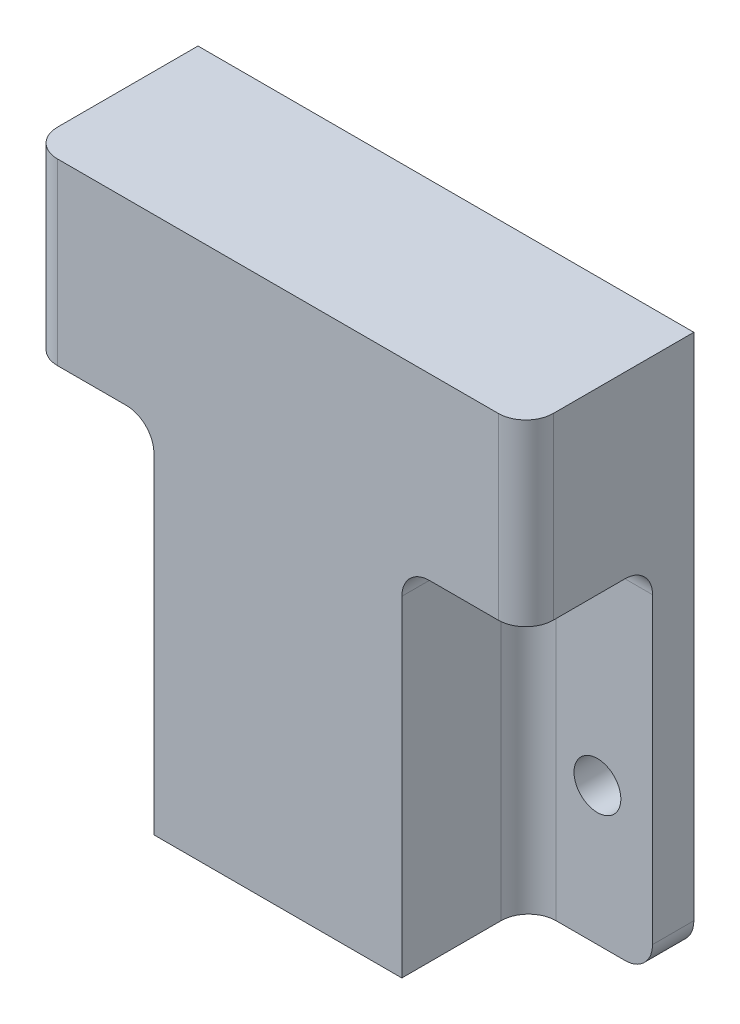
from build123d import *

# Parameters (mm, degrees)
SKIZZE1_W                       = 18
SKIZZE1_H                       = 10
AUFSATZ_LINEAR_AUSTRAGEN1_DEPTH = 3
DURCHGANGSLOCH_F_R_M31_D        = 3.4
SKIZZE5_W                       = 8
SKIZZE5_H                       = 3
AUFSATZ_LINEAR_AUSTRAGEN2_DEPTH = 3
AUFSATZ_LINEAR_AUSTRAGEN3_DEPTH = 10
AUFSATZ_LINEAR_AUSTRAGEN7_DEPTH = 9
SKIZZE19_W                      = 18
SKIZZE19_H                      = 3
AUFSATZ_LINEAR_AUSTRAGEN8_DEPTH = 9.2
VERRUNDUNG1_R                   = 2
VERRUNDUNG3_R                   = 2
AUFSATZ_LINEAR_AUSTRAGEN9_DEPTH = 10


with BuildPart() as part:
    # Skizze1 → Aufsatz-Linear austragen1 (new body)
    with BuildSketch(Plane.XY):
        with Locations((-9, 5)):
            Rectangle(SKIZZE1_W, SKIZZE1_H)
    extrude(amount=AUFSATZ_LINEAR_AUSTRAGEN1_DEPTH)

    # Durchgangsloch für M31 (through all)
    with Locations(Plane.XY.offset(3)):
        with Locations((-14, 0)):
            Hole(DURCHGANGSLOCH_F_R_M31_D / 2)

    # Skizze5 → Aufsatz-Linear austragen2 (add)
    with BuildSketch(Plane(origin=(0, 0, 0), x_dir=(-1, 0, 0), z_dir=(0, 0, -1))):
        with Locations((4, 1.5)):
            Rectangle(SKIZZE5_W, SKIZZE5_H)
    extrude(amount=AUFSATZ_LINEAR_AUSTRAGEN2_DEPTH)

    # Skizze7 → Aufsatz-Linear austragen3 (add)
    with BuildSketch(Plane(origin=(0, 10, 0), x_dir=(1, 0, 0), z_dir=(0, 1, 0))):
        Polygon((-6.5, -3), (-6.5, -9), (0, -9), (0, -12.2), (-9, -12.2), (-9, -3), align=None)
    extrude(amount=-AUFSATZ_LINEAR_AUSTRAGEN3_DEPTH)

    # Spiegeln2: part across plane


with BuildPart() as part_1:
    add(part.part)
    add(part.part.mirror(Plane(origin=(0, 0, 3), x_dir=(0, 0, 1), z_dir=(0, 1, 0))))

    # Skizze16 → Aufsatz-Linear austragen7 (add)
    with BuildSketch(Plane(origin=(0, 10, 0), x_dir=(1, 0, 0), z_dir=(0, 1, 0))):
        Polygon((0, 0), (-18, 0), (-18, -3), (-9, -3), (-9, -12.2), (0, -12.2), (0, -9), (-6.5, -9), (-6.5, -3), (0, -3), align=None)
    extrude(amount=AUFSATZ_LINEAR_AUSTRAGEN7_DEPTH)

    # Skizze19 → Aufsatz-Linear austragen8 (add)
    with BuildSketch(Plane.XY.offset(3)):
        with Locations((-9, 17.5)):
            Rectangle(SKIZZE19_W, SKIZZE19_H)
    extrude(amount=AUFSATZ_LINEAR_AUSTRAGEN8_DEPTH)

    # Verrundung1
    verrundung1_edges = [part_1.edges().sort_by_distance(p)[0] for p in [
        (-9, 16, 7.6),
        (-13.5, 16, 3),
        (-18, 17.5, 12.2),
        (-9, 5, 3),
    ]]
    fillet(verrundung1_edges, radius=VERRUNDUNG1_R)

    # Verrundung3
    verrundung3_edges = [part_1.edges().sort_by_distance(p)[0] for p in [
        (-18, -10, 1.5),
    ]]
    fillet(verrundung3_edges, radius=VERRUNDUNG3_R)

    # Spiegeln1: part across plane


with BuildPart() as part_2:
    add(part_1.part)
    add(part_1.part.mirror(Plane(origin=(0, 0, 3), x_dir=(0, 0, 1), z_dir=(-1, 0, 0))))

    # Skizze20 → Aufsatz-Linear austragen9 (add)
    with BuildSketch(Plane(origin=(0, 19, 0), x_dir=(1, 0, 0), z_dir=(0, 1, 0))):
        with BuildLine():
            Line((-18, 0), (-18, -10.2))
            ThreePointArc((-18, -10.2), (-17.414213562, -11.614213562), (-16, -12.2))
            Line((-16, -12.2), (16, -12.2))
            ThreePointArc((16, -12.2), (17.414213562, -11.614213562), (18, -10.2))
            Line((18, -10.2), (18, 0))
            Line((18, 0), (-18, 0))
        make_face()
    extrude(amount=AUFSATZ_LINEAR_AUSTRAGEN9_DEPTH)


solid = part_2.part
